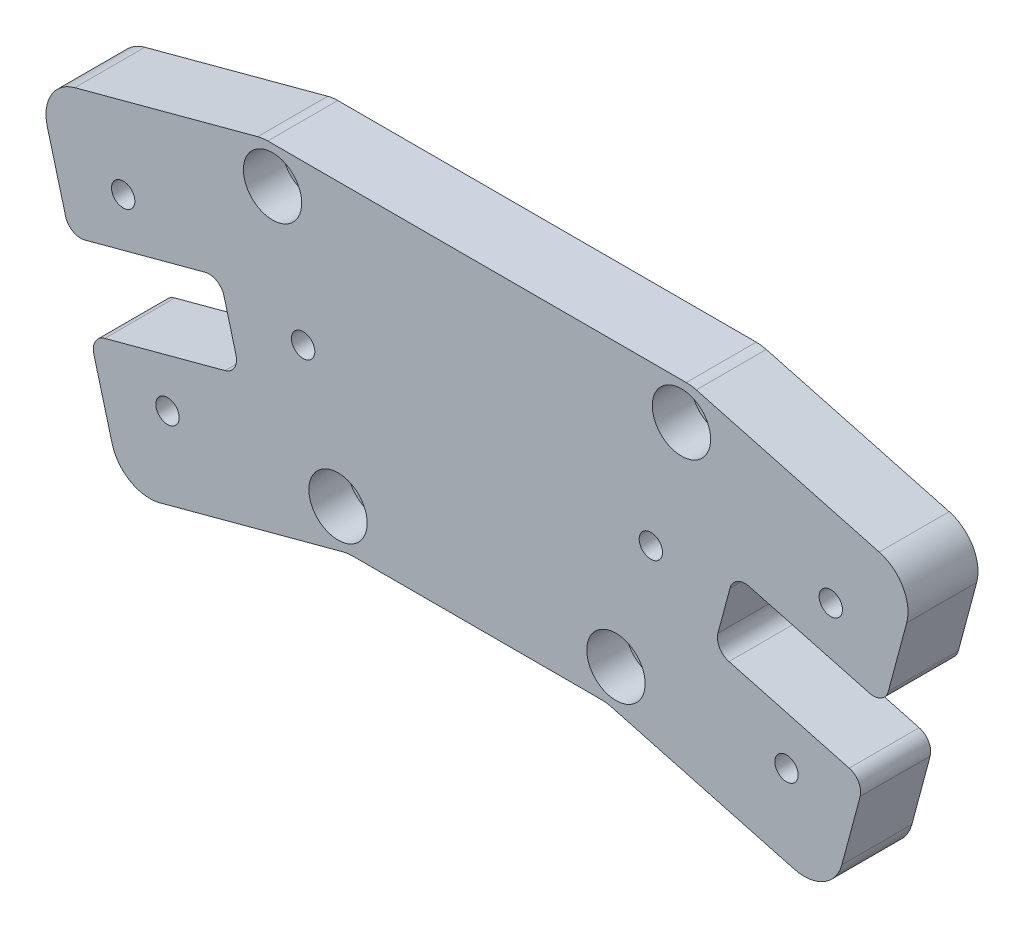
from build123d import *

# Parameters (mm, degrees)
SKETCH_1_R          = 1.75
SKETCH_1_R_2        = 1.5
EXTRUDE_1_DEPTH     = 9
FILLET_1_R          = 5
CUT_EXTRUDE_1_DEPTH = 3.5
SKETCH_5_R          = 3.75
CUT_EXTRUDE_2_DEPTH = 5
FILLET_2_R          = 2


with BuildPart() as part:
    # 草图1 → 凸台-拉伸1 (new body)
    with BuildSketch(Plane.XY):
        Polygon((-27.555241702, 0), (27.555241702, 0), (56.53301649, -7.764571353), (52.366592329, -23.31387801), (33.048075803, -18.137497108), (30.459885352, -27.796755371), (49.778401878, -32.973136273), (45.611977716, -48.52244293), (16.634202927, -40.757871577), (-16.634202927, -40.757871577), (-45.611977716, -48.52244293), (-49.778401878, -32.973136273), (-30.459885352, -27.796755371), (-33.048075803, -18.137497108), (-52.366592329, -23.31387801), (-56.53301649, -7.764571353), align=None)
        with Locations((-26.282483038, -4.75)):
            Circle(SKETCH_1_R, mode=Mode.SUBTRACT)
        with Locations((-17.863593392, -36.169723902)):
            Circle(SKETCH_1_R, mode=Mode.SUBTRACT)
        with Locations((17.863593392, -36.169723902)):
            Circle(SKETCH_1_R, mode=Mode.SUBTRACT)
        with Locations((26.282483038, -4.75)):
            Circle(SKETCH_1_R, mode=Mode.SUBTRACT)
        with Locations((-45.482028723, -15.257507669)):
            Circle(SKETCH_1_R_2, mode=Mode.SUBTRACT)
        with Locations((-22.350576875, -20.447491811)):
            Circle(SKETCH_1_R_2, mode=Mode.SUBTRACT)
        with Locations((-39.788009731, -36.507875848)):
            Circle(SKETCH_1_R_2, mode=Mode.SUBTRACT)
        with Locations((45.482028723, -15.257507669)):
            Circle(SKETCH_1_R_2, mode=Mode.SUBTRACT)
        with Locations((39.788009731, -36.507875848)):
            Circle(SKETCH_1_R_2, mode=Mode.SUBTRACT)
        with Locations((22.350576875, -20.447491811)):
            Circle(SKETCH_1_R_2, mode=Mode.SUBTRACT)
    extrude(amount=EXTRUDE_1_DEPTH)

    # 圆角1
    fillet_1_edges = [part.edges().sort_by_distance(p)[0] for p in [
        (-45.611977716, -48.52244293, 4.5),
        (-56.53301649, -7.764571353, 4.5),
        (-27.555241702, 0, 4.5),
        (27.555241702, 0, 4.5),
        (56.53301649, -7.764571353, 4.5),
        (45.611977716, -48.52244293, 4.5),
        (16.634202927, -40.757871577, 4.5),
        (-16.634202927, -40.757871577, 4.5),
    ]]
    fillet(fillet_1_edges, radius=FILLET_1_R)

    # 草图2 → 切除-拉伸1 (cut)
    with BuildSketch(Plane(origin=(0, 0, 0), x_dir=(-1, 0, 0), z_dir=(0, 0, -1))):
        Polygon((-42.303266769, -14.405760971), (-44.630282024, -12.078745715), (-47.809043978, -12.930492414), (-48.660790677, -16.109254368), (-46.333775421, -18.436269623), (-43.155013467, -17.584522925), align=None)
        Polygon((-21.498830176, -23.626253766), (-19.17181492, -21.29923851), (-20.023561619, -18.120476556), (-23.202323573, -17.268729857), (-25.529338829, -19.595745113), (-24.67759213, -22.774507067), align=None)
        Polygon((-36.609247776, -35.656129149), (-38.936263032, -33.329113893), (-42.115024986, -34.180860592), (-42.966771685, -37.359622546), (-40.639756429, -39.686637802), (-37.460994475, -38.834891103), align=None)
        Polygon((37.460994475, -38.834891103), (36.609247776, -35.656129149), (38.936263032, -33.329113893), (42.115024986, -34.180860592), (42.966771685, -37.359622546), (40.639756429, -39.686637802), align=None)
        Polygon((43.155013467, -17.584522925), (42.303266769, -14.405760971), (44.630282024, -12.078745715), (47.809043978, -12.930492414), (48.660790677, -16.109254368), (46.333775421, -18.436269623), align=None)
        Polygon((24.67759213, -22.774507067), (21.498830176, -23.626253766), (19.17181492, -21.29923851), (20.023561619, -18.120476556), (23.202323573, -17.268729857), (25.529338829, -19.595745113), align=None)
    extrude(amount=-CUT_EXTRUDE_1_DEPTH, mode=Mode.SUBTRACT)

    # 草图5 → 切除-拉伸2 (cut)
    with BuildSketch(Plane.XY.offset(9)):
        with Locations((-26.282483038, -4.75)):
            Circle(SKETCH_5_R)
        with Locations((-17.863593392, -36.169723902)):
            Circle(SKETCH_5_R)
        with Locations((17.863593392, -36.169723902)):
            Circle(SKETCH_5_R)
        with Locations((26.282483038, -4.75)):
            Circle(SKETCH_5_R)
    extrude(amount=-CUT_EXTRUDE_2_DEPTH, mode=Mode.SUBTRACT)

    # 圆角2
    fillet_2_edges = [part.edges().sort_by_distance(p)[0] for p in [
        (-49.778401878, -32.973136273, 4.5),
        (-30.459885352, -27.796755371, 4.5),
        (-33.048075803, -18.137497108, 4.5),
        (-52.366592329, -23.31387801, 4.5),
        (52.366592329, -23.31387801, 4.5),
        (33.048075803, -18.137497108, 4.5),
        (30.459885352, -27.796755371, 4.5),
        (49.778401878, -32.973136273, 4.5),
    ]]
    fillet(fillet_2_edges, radius=FILLET_2_R)


solid = part.part
